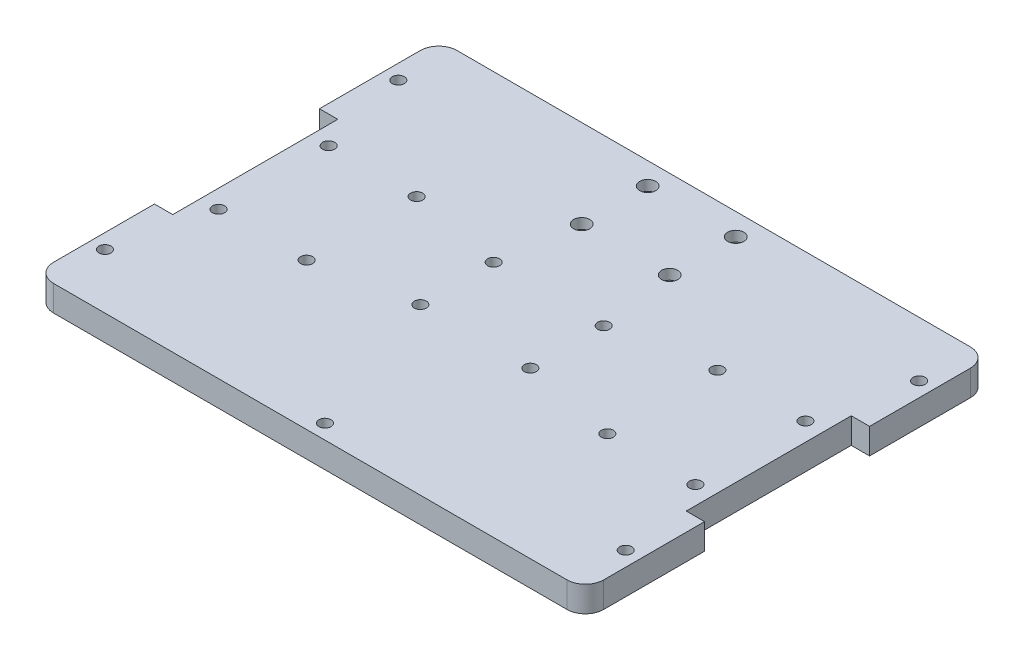
from build123d import *

# Parameters (mm, degrees)
SKETCH_1_W          = 150
SKETCH_1_H          = 110
EXTRUDE_1_DEPTH     = 7
FILLET_1_R          = 5
SKETCH_2_R          = 1.65
SKETCH_2_R_2        = 2.2
CUT_EXTRUDE_1_DEPTH = 8
SKETCH_5_R          = 3.75
CUT_EXTRUDE_3_DEPTH = 4.2
CUT_EXTRUDE_4_DEPTH = 3
SKETCH_7_R          = 2.9
CUT_EXTRUDE_5_DEPTH = 3.3
SKETCH_8_R          = 1.65
CUT_EXTRUDE_6_DEPTH = 8
SKETCH_9_R          = 2.9
CUT_EXTRUDE_7_DEPTH = 4
SKETCH_10_W         = 5
SKETCH_10_H         = 45
CUT_EXTRUDE_8_DEPTH = 8


with BuildPart() as part:
    # 草图1 → 凸台-拉伸1 (new body)
    with BuildSketch(Plane(origin=(0, 0, 0), x_dir=(1, 0, 0), z_dir=(0, 1, 0))):
        Rectangle(SKETCH_1_W, SKETCH_1_H)
    extrude(amount=EXTRUDE_1_DEPTH)

    # 圆角1
    fillet_1_edges = [part.edges().sort_by_distance(p)[0] for p in [
        (75, 3.5, 55),
        (-75, 3.5, 55),
        (-75, 3.5, -55),
        (75, 3.5, -55),
    ]]
    fillet(fillet_1_edges, radius=FILLET_1_R)

    # 草图2 → 切除-拉伸1 (cut, through all)
    with BuildSketch(Plane(origin=(0, 7, 0), x_dir=(1, 0, 0), z_dir=(0, 1, 0))):
        with Locations((65, -15)):
            Circle(SKETCH_2_R)
        with Locations((41, -15)):
            Circle(SKETCH_2_R)
        with Locations((41, 15)):
            Circle(SKETCH_2_R)
        with Locations((65, 15)):
            Circle(SKETCH_2_R)
        with Locations((-65, 15)):
            Circle(SKETCH_2_R)
        with Locations((-41, 15)):
            Circle(SKETCH_2_R)
        with Locations((-41, -15)):
            Circle(SKETCH_2_R)
        with Locations((-65, -15)):
            Circle(SKETCH_2_R)
        with Locations((12, 31)):
            Circle(SKETCH_2_R_2)
        with Locations((12, 49)):
            Circle(SKETCH_2_R_2)
        with Locations((-12, 49)):
            Circle(SKETCH_2_R_2)
        with Locations((-12, 31)):
            Circle(SKETCH_2_R_2)
        with Locations((15, 10)):
            Circle(SKETCH_2_R)
        with Locations((15, -10)):
            Circle(SKETCH_2_R)
        with Locations((-15, -10)):
            Circle(SKETCH_2_R)
        with Locations((-15, 10)):
            Circle(SKETCH_2_R)
    extrude(amount=-CUT_EXTRUDE_1_DEPTH, mode=Mode.SUBTRACT)

    # 草图5 → 切除-拉伸3 (cut)
    with BuildSketch(Plane.XZ):
        with Locations((12, -49)):
            Circle(SKETCH_5_R)
        with Locations((12, -31)):
            Circle(SKETCH_5_R)
        with Locations((-12, -31)):
            Circle(SKETCH_5_R)
        with Locations((-12, -49)):
            Circle(SKETCH_5_R)
    extrude(amount=-CUT_EXTRUDE_3_DEPTH, mode=Mode.SUBTRACT)

    # 草图6 → 切除-拉伸4 (cut)
    with BuildSketch(Plane.XZ):
        Polygon((-39.325684219, 17.9), (-37.651368439, 15), (-39.325684219, 12.1), (-42.674315781, 12.1), (-44.348631561, 15), (-42.674315781, 17.9), align=None)
        Polygon((61.651368439, -15), (63.325684219, -17.9), (66.674315781, -17.9), (68.348631561, -15), (66.674315781, -12.1), (63.325684219, -12.1), align=None)
        Polygon((37.651368439, -15), (39.325684219, -17.9), (42.674315781, -17.9), (44.348631561, -15), (42.674315781, -12.1), (39.325684219, -12.1), align=None)
        Polygon((61.651368439, 15), (63.325684219, 12.1), (66.674315781, 12.1), (68.348631561, 15), (66.674315781, 17.9), (63.325684219, 17.9), align=None)
        Polygon((37.651368439, 15), (39.325684219, 12.1), (42.674315781, 12.1), (44.348631561, 15), (42.674315781, 17.9), (39.325684219, 17.9), align=None)
        Polygon((-63.325684219, 17.9), (-61.651368439, 15), (-63.325684219, 12.1), (-66.674315781, 12.1), (-68.348631561, 15), (-66.674315781, 17.9), align=None)
        Polygon((-39.325684219, -12.1), (-37.651368439, -15), (-39.325684219, -17.9), (-42.674315781, -17.9), (-44.348631561, -15), (-42.674315781, -12.1), align=None)
        Polygon((-63.325684219, -12.1), (-61.651368439, -15), (-63.325684219, -17.9), (-66.674315781, -17.9), (-68.348631561, -15), (-66.674315781, -12.1), align=None)
    extrude(amount=-CUT_EXTRUDE_4_DEPTH, mode=Mode.SUBTRACT)

    # 草图7 → 切除-拉伸5 (cut)
    with BuildSketch(Plane.XZ):
        with Locations((15, -10)):
            Circle(SKETCH_7_R)
        with Locations((15, 10)):
            Circle(SKETCH_7_R)
        with Locations((-15, 10)):
            Circle(SKETCH_7_R)
        with Locations((-15, -10)):
            Circle(SKETCH_7_R)
    extrude(amount=-CUT_EXTRUDE_5_DEPTH, mode=Mode.SUBTRACT)

    # 草图8 → 切除-拉伸6 (cut, through all)
    with BuildSketch(Plane.XZ):
        with Locations((71, 40)):
            Circle(SKETCH_8_R)
        with Locations((71, -40)):
            Circle(SKETCH_8_R)
        with Locations((-71, -40)):
            Circle(SKETCH_8_R)
        with Locations((-71, 40)):
            Circle(SKETCH_8_R)
        with Locations((0, 51)):
            Circle(SKETCH_8_R)
    extrude(amount=-CUT_EXTRUDE_6_DEPTH, mode=Mode.SUBTRACT)

    # 草图9 → 切除-拉伸7 (cut)
    with BuildSketch(Plane.XZ):
        with Locations((71, 40)):
            Circle(SKETCH_9_R)
        with Locations((71, -40)):
            Circle(SKETCH_9_R)
        with Locations((-71, 40)):
            Circle(SKETCH_9_R)
        with Locations((-71, -40)):
            Circle(SKETCH_9_R)
        with Locations((0, 51)):
            Circle(SKETCH_9_R)
    extrude(amount=-CUT_EXTRUDE_7_DEPTH, mode=Mode.SUBTRACT)

    # 草图10 → 切除-拉伸8 (cut, through all)
    with BuildSketch(Plane(origin=(0, 7, 0), x_dir=(1, 0, 0), z_dir=(0, 1, 0))):
        with Locations((72.5, 0)):
            Rectangle(SKETCH_10_W, SKETCH_10_H)
        with Locations((-72.5, 0)):
            Rectangle(SKETCH_10_W, SKETCH_10_H)
    extrude(amount=-CUT_EXTRUDE_8_DEPTH, mode=Mode.SUBTRACT)


solid = part.part
